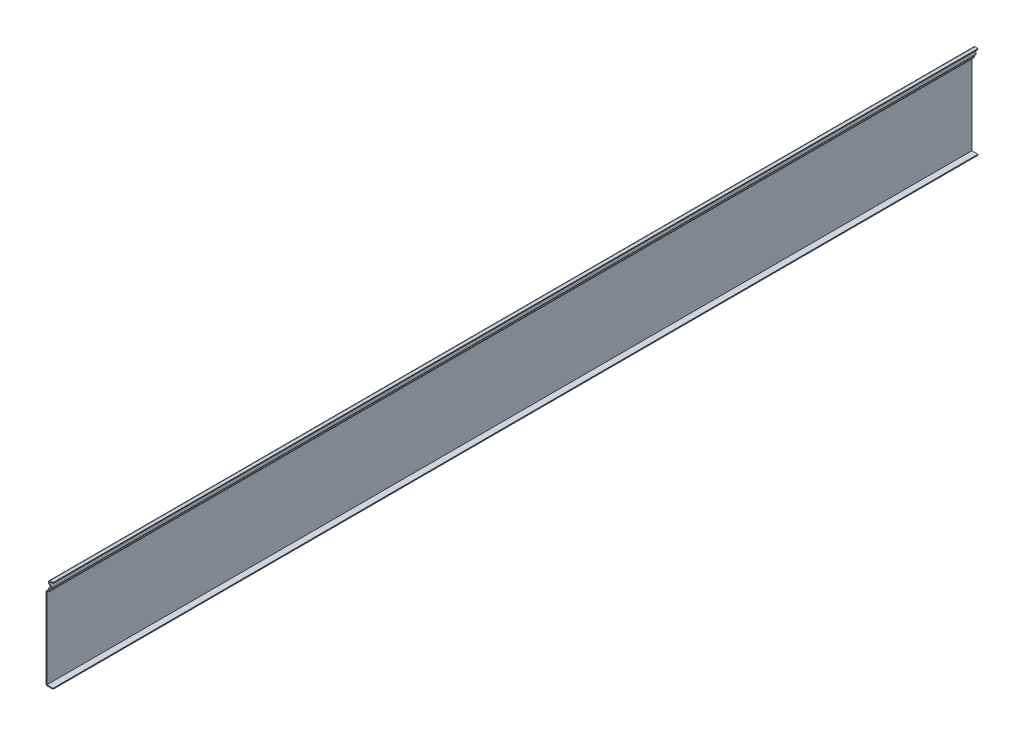
from build123d import *

# Parameters (mm, degrees)
EXTRUDE_THIN1_DEPTH = 1254.125
FILLET1_R           = 1.27


with BuildPart() as part:
    # Sketch1 → Extrude-Thin1 (new body)
    with BuildSketch(Plane.XY):
        with BuildLine():
            Line((0, 0), (-9.525, 0))
            Line((-9.525, 0), (-9.525, 109.5375))
            ThreePointArc((-9.525, 109.5375), (-8.59506403, 111.78256403), (-6.35, 112.7125))
            Line((-6.35, 112.7125), (-6.35, 115.8875))
            ThreePointArc((-6.35, 115.8875), (-3.884748595, 117.779153935), (-5.073891971, 120.65))
            ThreePointArc((-5.073891971, 120.65), (-6.263035347, 123.520846065), (-3.797783942, 125.4125))
            Line((-3.797783942, 125.4125), (0, 125.4125))
            Line((0, 125.4125), (0, 124.1425))
            Line((0, 124.1425), (-3.797783942, 124.1425))
            ThreePointArc((-3.797783942, 124.1425), (-5.036309547, 123.192145878), (-4.438891971, 121.749852263))
            ThreePointArc((-4.438891971, 121.749852263), (-2.544105078, 118.08687128), (-5.08, 114.834659111))
            Line((-5.08, 114.834659111), (-5.08, 110.957403166))
            ThreePointArc((-5.08, 110.957403166), (-7.127712993, 111.27651912), (-8.255, 109.5375))
            Line((-8.255, 109.5375), (-8.255, 1.27))
            Line((-8.255, 1.27), (0, 1.27))
            Line((0, 1.27), (0, 0))
        make_face()
    extrude(amount=-EXTRUDE_THIN1_DEPTH)

    # Fillet1
    fillet1_edges = [part.edges().sort_by_distance(p)[0] for p in [
        (-5.08, 110.957403166, -627.0625),
        (-9.525, 0, -627.0625),
        (-6.35, 115.8875, -627.0625),
    ]]
    fillet(fillet1_edges, radius=FILLET1_R)


solid = part.part
